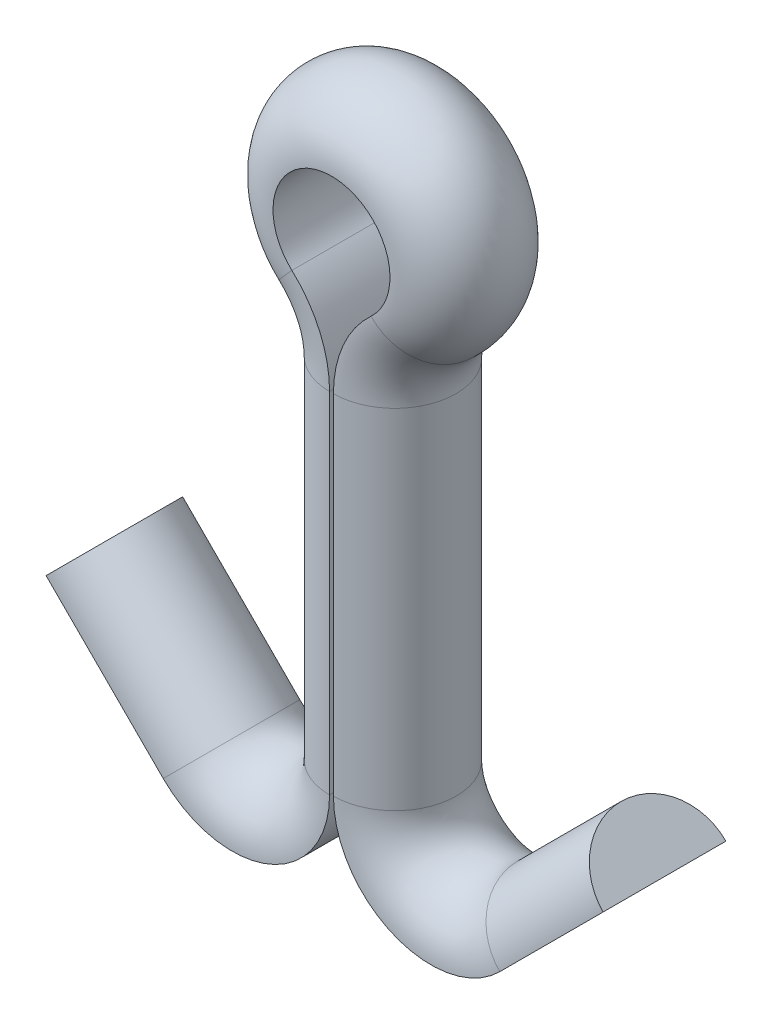
from build123d import *


with BuildPart() as part:
    # Pin: sweep along a path in Sketch1
    with BuildLine(Plane.XY) as pin_path:
        Line((0.025, -6.223), (0.025, -1.681188568))
        ThreePointArc((0.025, -1.681188568), (0.153227812, -1.069309495), (0.516333333, -0.560396189))
        ThreePointArc((0.516333333, -0.560396189), (0, 0.762), (-0.516333333, -0.560396189))
        ThreePointArc((-0.516333333, -0.560396189), (-0.153227812, -1.069309495), (-0.025, -1.681188568))
        Line((-0.025, -1.681188568), (-0.025, -6.2357))
        ThreePointArc((-0.025, -6.2357), (-0.808992041, -7.409027006), (-2.193025612, -7.133725612))
        Line((-2.193025612, -7.133725612), (-3.719669153, -5.607082072))
    # Sketch2 → Pin (sweep)
    with BuildSketch(Plane(origin=(0.025, -6.223, 0), x_dir=(1, 0, 0), z_dir=(0, -1, 0))):
        with BuildLine():
            Line((0, 0.8001), (0, -0.8001))
            ThreePointArc((0, -0.8001), (0.8001, 0), (0, 0.8001))
        make_face()
    sweep(path=pin_path.line)

    # Sweep1: sweep along a path in Sketch3
    with BuildLine(Plane.XY) as sweep1_path:
        Line((3.54006403, -5.773987194), (2.193025612, -7.121025612))
        ThreePointArc((2.193025612, -7.121025612), (0.808992041, -7.396327006), (0.025, -6.223))
    # Sketch4 → Sweep1 (sweep)
    with BuildSketch(Plane.XZ.offset(6.223)):
        with BuildLine():
            Line((0.025, 0.8001), (0.025, -0.8001))
            ThreePointArc((0.025, -0.8001), (0.8251, 0), (0.025, 0.8001))
        make_face()
    sweep(path=sweep1_path.line)


solid = part.part
